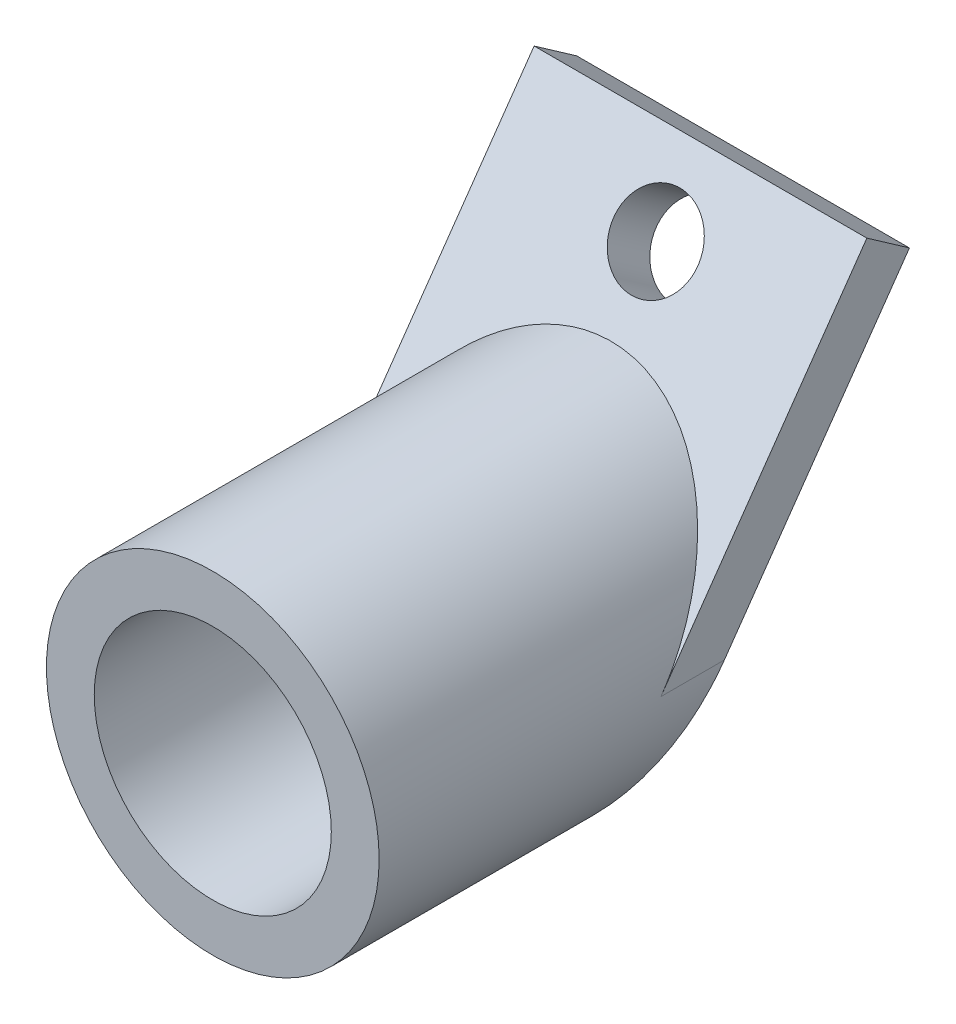
from build123d import *

# Parameters (mm, degrees)
SKETCH1_R                = 16
SKETCH1_R_2              = 11.4
BOSS_EXTRUDE1_DEPTH      = 20
SKETCH2_R                = 16
BOSS_EXTRUDE2_DEPTH      = 2
BOSS_EXTRUDE3_DEPTH      = 16
BOSS_EXTRUDE3_DEPTH_BACK = 16
CUT_EXTRUDE1_DEPTH       = 30.002175046
BOSS_EXTRUDE4_REACH      = 31.002
SKETCH5_R                = 16
SKETCH6_R                = 4.05
CUT_EXTRUDE3_DEPTH       = 29.757190977


with BuildPart() as part:
    # Sketch1 → Boss-Extrude1 (new body)
    with BuildSketch(Plane.XY):
        Circle(SKETCH1_R)
        Circle(SKETCH1_R_2, mode=Mode.SUBTRACT)
    extrude(amount=BOSS_EXTRUDE1_DEPTH)

    # Sketch2 → Boss-Extrude2 (add)
    with BuildSketch(Plane(origin=(0, 0, 0), x_dir=(-1, 0, 0), z_dir=(0, 0, -1))):
        Circle(SKETCH2_R)
    extrude(amount=BOSS_EXTRUDE2_DEPTH)

    # Sketch3 → Boss-Extrude3 (add, two sides)
    with BuildSketch(Plane(origin=(0, 0, 0), x_dir=(0, 0, -1), z_dir=(1, 0, 0))) as boss_extrude3_sk:
        Polygon((31.002175046, 25.419398483), (26.906414824, 28.287280664), (18.302768279, 16), (2, -7.282766022), (2, -16), align=None)
    extrude(amount=BOSS_EXTRUDE3_DEPTH)
    extrude(boss_extrude3_sk.sketch, amount=-BOSS_EXTRUDE3_DEPTH_BACK)

    # Sketch4 → Cut-Extrude1 (cut, through all)
    with BuildSketch(Plane(origin=(0, 0, -2), x_dir=(-1, 0, 0), z_dir=(0, 0, -1))):
        with BuildLine():
            Line((34.266518051, 0), (16, 0))
            ThreePointArc((16, 0), (15.555436181, -3.745451268), (14.24644935, -7.282766022))
            ThreePointArc((14.24644935, -7.282766022), (0, -16), (-14.24644935, -7.282766022))
            ThreePointArc((-14.24644935, -7.282766022), (-15.555436181, -3.745451268), (-16, 0))
            Line((-16, 0), (-34.430612934, 0))
            Line((-34.430612934, 0), (-36.46308972, -20.488677285))
            Line((-36.46308972, -20.488677285), (32.179774964, -27.298049462))
            Line((32.179774964, -27.298049462), (34.266518051, 0))
        make_face()
    extrude(amount=CUT_EXTRUDE1_DEPTH, mode=Mode.SUBTRACT)

    # Sketch5 → Boss-Extrude4 (add, up to next)
    with BuildSketch(Plane(origin=(0, 0, -2), x_dir=(-1, 0, 0), z_dir=(0, 0, -1)), mode=Mode.PRIVATE) as boss_extrude4_sk1:
        Circle(SKETCH5_R)
    boss_extrude4_tool1 = extrude(boss_extrude4_sk1.sketch, amount=BOSS_EXTRUDE4_REACH, mode=Mode.PRIVATE) - part.part
    add(boss_extrude4_tool1.solids().sort_by_distance((0, 0, -2))[0])

    # Sketch6 → Cut-Extrude3 (cut, through all)
    with BuildSketch(Plane(origin=(0, -3.335649292, -4.763800888), x_dir=(1, 0, 0), z_dir=(0, 0.573576436, 0.819152044))):
        with Locations((0, 31.104469313)):
            Circle(SKETCH6_R)
    extrude(amount=-CUT_EXTRUDE3_DEPTH, mode=Mode.SUBTRACT)


solid = part.part
